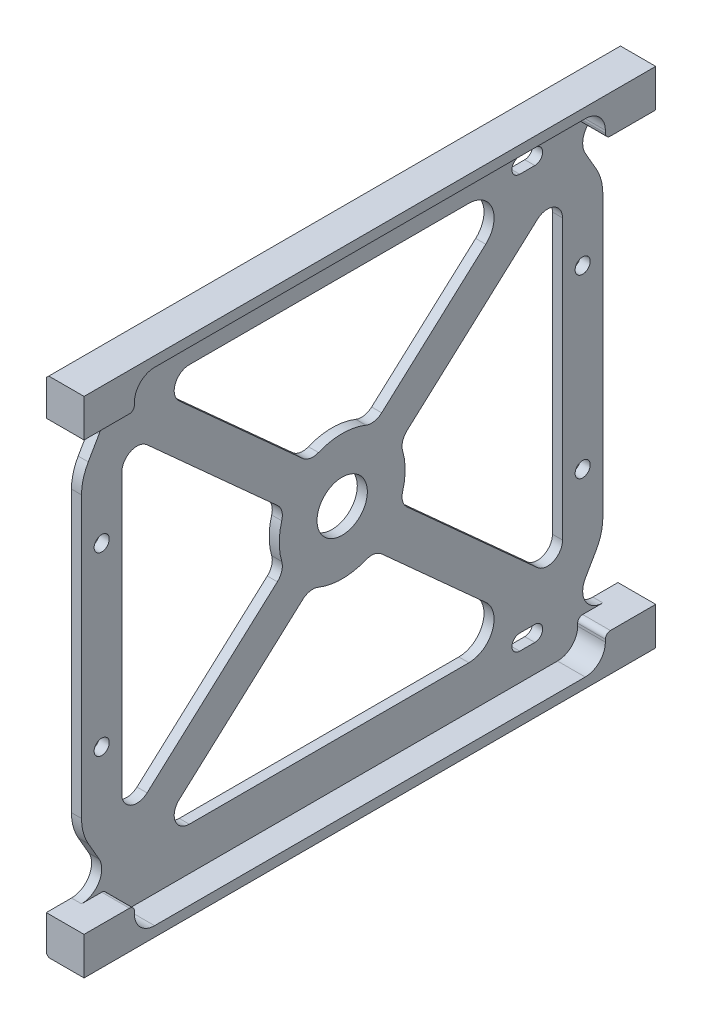
from build123d import *

# Parameters (mm, degrees)
BOSS_EXTRUDE1_DEPTH = 56.75
SKETCH2_W           = 5
SKETCH2_H           = 85
SKETCH2_R           = 1.5
CUT_EXTRUDE1_DEPTH  = 2
SKETCH3_R           = 5
CUT_EXTRUDE2_DEPTH  = 3
CHAMFER1_SIZE       = 0.5
CUT_EXTRUDE3_DEPTH  = 5.5
CUT_EXTRUDE4_DEPTH  = 10


with BuildPart() as part:
    # Sketch1 → Boss-Extrude1 (new body, symmetric)
    with BuildSketch(Plane.XY):
        Polygon((0, 50), (0, -50), (7.5, -50), (7.5, -42.5), (2, -42.5), (2, 42.5), (7.5, 42.5), (7.5, 50), align=None)
    extrude(amount=BOSS_EXTRUDE1_DEPTH, both=True)

    # Sketch2 → Cut-Extrude1 (cut)
    with BuildSketch(Plane(origin=(2, 0, 0), x_dir=(0, 0, -1), z_dir=(1, 0, 0))):
        with Locations((-54.25, 0)):
            Rectangle(SKETCH2_W, SKETCH2_H)
        with Locations((54.25, 0)):
            Rectangle(SKETCH2_W, SKETCH2_H)
        with Locations((-47.75, 17.5)):
            Circle(SKETCH2_R)
        with Locations((-47.75, -17.5)):
            Circle(SKETCH2_R)
        with Locations((47.75, 17.5)):
            Circle(SKETCH2_R)
        with Locations((47.75, -17.5)):
            Circle(SKETCH2_R)
    extrude(amount=-CUT_EXTRUDE1_DEPTH, mode=Mode.SUBTRACT)

    # Sketch3 → Cut-Extrude2 (cut, through all)
    with BuildSketch(Plane(origin=(2, 0, 0), x_dir=(0, 0, -1), z_dir=(1, 0, 0))):
        Circle(SKETCH3_R)
        with BuildLine():
            Line((-30.354626116, -39.5), (25.154965406, -39.5))
            ThreePointArc((25.154965406, -39.5), (29.821654194, -36.294997423), (28.505643146, -30.7888063))
            Line((28.505643146, -30.7888063), (7.843483172, -12.13382758))
            ThreePointArc((7.843483172, -12.13382758), (6.353277021, -11.405989443), (4.704093974, -11.58108371))
            ThreePointArc((4.704093974, -11.58108371), (0, -12.5), (-4.704093974, -11.58108371))
            ThreePointArc((-4.704093974, -11.58108371), (-6.353277021, -11.405989443), (-7.843483172, -12.13382758))
            Line((-7.843483172, -12.13382758), (-32.36503276, -34.27328378))
            ThreePointArc((-32.36503276, -34.27328378), (-33.154639389, -37.576998454), (-30.354626116, -39.5))
        make_face()
        with BuildLine():
            Line((-43.75, -27.697319579), (-43.75, 27.697319579))
            ThreePointArc((-43.75, 27.697319579), (-41.968355463, 30.438780862), (-38.739593356, 29.924035799))
            Line((-38.739593356, 29.924035799), (-12.869499782, 6.56703703))
            ThreePointArc((-12.869499782, 6.56703703), (-11.993687913, 5.158698897), (-11.999924538, 3.500258718))
            ThreePointArc((-11.999924538, 3.500258718), (-12.5, 0), (-11.999924538, -3.500258718))
            ThreePointArc((-11.999924538, -3.500258718), (-11.993687913, -5.158698897), (-12.869499782, -6.56703703))
            Line((-12.869499782, -6.56703703), (-38.739593356, -29.924035799))
            ThreePointArc((-38.739593356, -29.924035799), (-41.968355463, -30.438780862), (-43.75, -27.697319579))
        make_face()
        with BuildLine():
            Line((-30.354626116, 39.5), (25.154965406, 39.5))
            ThreePointArc((25.154965406, 39.5), (29.821654194, 36.294997423), (28.505643146, 30.7888063))
            Line((28.505643146, 30.7888063), (7.843483172, 12.13382758))
            ThreePointArc((7.843483172, 12.13382758), (6.353277021, 11.405989443), (4.704093974, 11.58108371))
            ThreePointArc((4.704093974, 11.58108371), (0, 12.5), (-4.704093974, 11.58108371))
            ThreePointArc((-4.704093974, 11.58108371), (-6.353277021, 11.405989443), (-7.843483172, 12.13382758))
            Line((-7.843483172, 12.13382758), (-32.36503276, 34.27328378))
            ThreePointArc((-32.36503276, 34.27328378), (-33.154639389, 37.576998454), (-30.354626116, 39.5))
        make_face()
        with BuildLine():
            Line((43.75, -27.697319579), (43.75, 27.697319579))
            ThreePointArc((43.75, 27.697319579), (41.968355463, 30.438780862), (38.739593356, 29.924035799))
            Line((38.739593356, 29.924035799), (12.869499782, 6.56703703))
            ThreePointArc((12.869499782, 6.56703703), (11.993687913, 5.158698897), (11.999924538, 3.500258718))
            ThreePointArc((11.999924538, 3.500258718), (12.5, 0), (11.999924538, -3.500258718))
            ThreePointArc((11.999924538, -3.500258718), (11.993687913, -5.158698897), (12.869499782, -6.56703703))
            Line((12.869499782, -6.56703703), (38.739593356, -29.924035799))
            ThreePointArc((38.739593356, -29.924035799), (41.968355463, -30.438780862), (43.75, -27.697319579))
        make_face()
        with BuildLine():
            Line((35.25, -39.45), (38.25, -39.45))
            ThreePointArc((38.25, -39.45), (39.8, -41), (38.25, -42.55))
            Line((38.25, -42.55), (35.25, -42.55))
            ThreePointArc((35.25, -42.55), (33.7, -41), (35.25, -39.45))
        make_face()
        with BuildLine():
            Line((35.25, 42.55), (38.25, 42.55))
            ThreePointArc((38.25, 42.55), (39.8, 41), (38.25, 39.45))
            Line((38.25, 39.45), (35.25, 39.45))
            ThreePointArc((35.25, 39.45), (33.7, 41), (35.25, 42.55))
        make_face()
    extrude(amount=-CUT_EXTRUDE2_DEPTH, mode=Mode.SUBTRACT)

    # Chamfer1
    chamfer1_edges = [part.edges().sort_by_distance(p)[0] for p in [
        (0, -50, 0),
        (0, 50, 0),
    ]]
    chamfer(chamfer1_edges, length=CHAMFER1_SIZE)

    # Sketch4 → Cut-Extrude3 (cut)
    with BuildSketch(Plane(origin=(7.5, 0, 0), x_dir=(0, 0, -1), z_dir=(1, 0, 0))):
        with BuildLine():
            Line((42.75, -48), (-42.75, -48))
            ThreePointArc((-42.75, -48), (-45.578427125, -46.828427125), (-46.75, -44))
            Line((-46.75, -44), (-46.75, -43.5))
            ThreePointArc((-46.75, -43.5), (-47.042893219, -42.792893219), (-47.75, -42.5))
            Line((-47.75, -42.5), (47.75, -42.5))
            ThreePointArc((47.75, -42.5), (47.042893219, -42.792893219), (46.75, -43.5))
            Line((46.75, -43.5), (46.75, -44))
            ThreePointArc((46.75, -44), (45.578427125, -46.828427125), (42.75, -48))
        make_face()
        with BuildLine():
            Line((-46.75, 44), (-46.75, 43.5))
            ThreePointArc((-46.75, 43.5), (-47.042893219, 42.792893219), (-47.75, 42.5))
            Line((-47.75, 42.5), (47.75, 42.5))
            ThreePointArc((47.75, 42.5), (47.042893219, 42.792893219), (46.75, 43.5))
            Line((46.75, 43.5), (46.75, 44))
            ThreePointArc((46.75, 44), (45.578427125, 46.828427125), (42.75, 48))
            Line((42.75, 48), (-42.75, 48))
            ThreePointArc((-42.75, 48), (-45.578427125, 46.828427125), (-46.75, 44))
        make_face()
    extrude(amount=-CUT_EXTRUDE3_DEPTH, mode=Mode.SUBTRACT)

    # Sketch5 → Cut-Extrude4 (cut)
    with BuildSketch(Plane.ZY):
        with BuildLine():
            ThreePointArc((-51.75, 27.820508076), (-51.409258263, 30.408698527), (-50.410254038, 32.820508076))
            Line((-50.410254038, 32.820508076), (-48.285898385, 36.5))
            ThreePointArc((-48.285898385, 36.5), (-48.285898385, 40.5), (-51.75, 42.5))
            Line((-51.75, 42.5), (-51.75, 27.820508076))
        make_face()
        with BuildLine():
            ThreePointArc((-50.410254038, -32.820508076), (-51.409258263, -30.408698527), (-51.75, -27.820508076))
            Line((-51.75, -27.820508076), (-51.75, -42.5))
            ThreePointArc((-51.75, -42.5), (-48.285898385, -40.5), (-48.285898385, -36.5))
            Line((-48.285898385, -36.5), (-50.410254038, -32.820508076))
        make_face()
    cut_extrude4 = extrude(amount=-CUT_EXTRUDE4_DEPTH, mode=Mode.SUBTRACT)

    # Mirror1: Cut-Extrude4 across plane
    add(cut_extrude4.mirror(Plane.XY), mode=Mode.SUBTRACT)


solid = part.part
